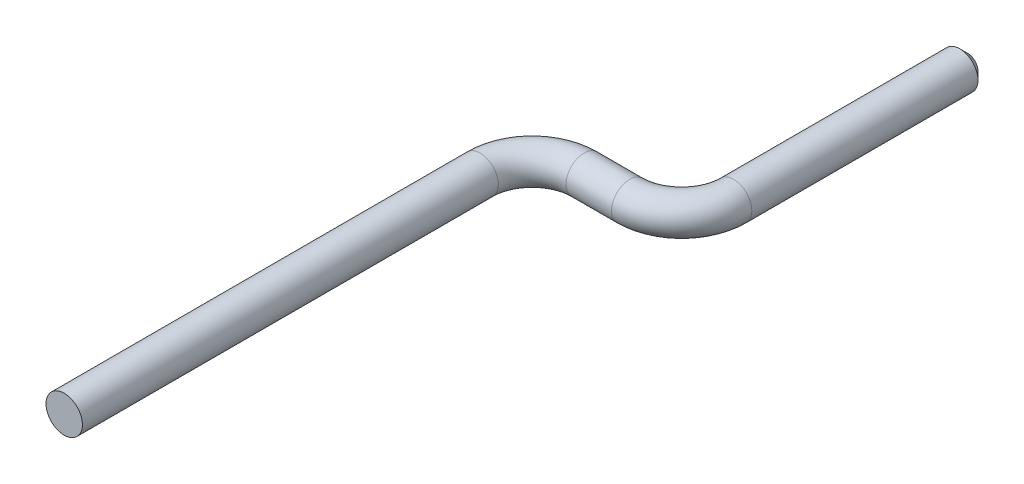
from build123d import *

# Parameters (mm, degrees)
SKETCH2_R     = 0.7
CHAMFER1_SIZE = 0.3


with BuildPart() as part:
    # Sweep1: sweep along a path in Sketch1
    with BuildLine(Plane(origin=(0, 0, 0), x_dir=(1, 0, 0), z_dir=(0, 1, 0))) as sweep1_path:
        Line((0, 0), (0, 16))
        ThreePointArc((0, 16), (0.585786438, 17.414213562), (2, 18))
        Line((2, 18), (3.75, 18))
        ThreePointArc((3.75, 18), (5.164213562, 18.585786438), (5.75, 20))
        Line((5.75, 20), (5.75, 29))
    # Sketch2 → Sweep1 (sweep)
    with BuildSketch(Plane.XY):
        Circle(SKETCH2_R)
    sweep(path=sweep1_path.line)

    # Chamfer1
    chamfer1_edges = [part.edges().sort_by_distance(p)[0] for p in [
        (5.05, 0, -29),
    ]]
    chamfer(chamfer1_edges, length=CHAMFER1_SIZE)


solid = part.part
